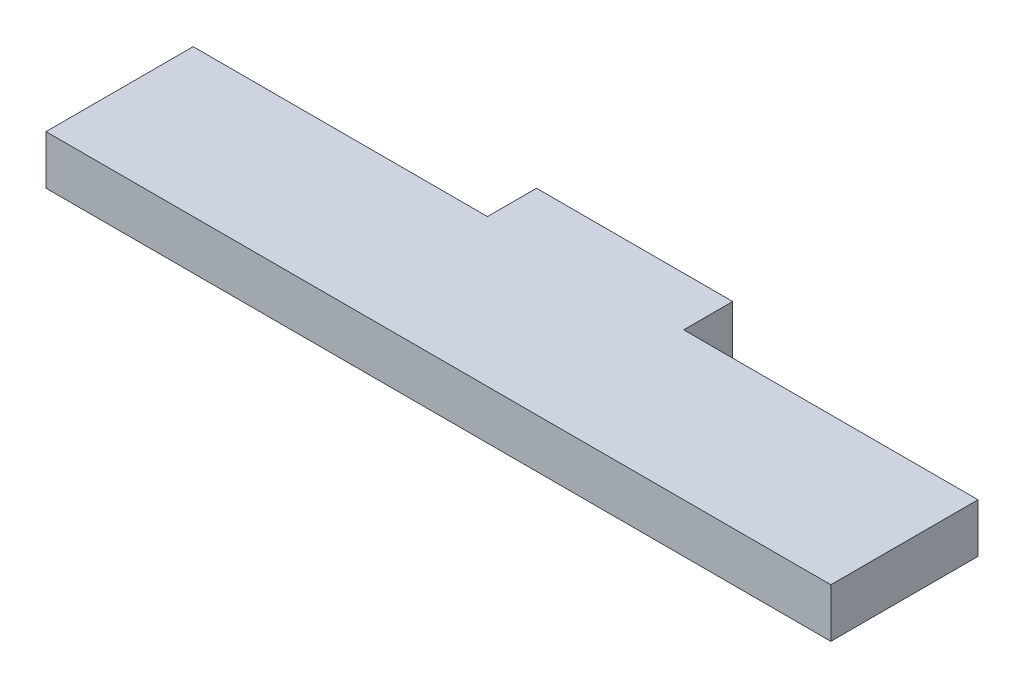
from build123d import *

# Parameters (mm, degrees)
SKETCH1_W               = 101.6
SKETCH1_H               = 25.4
BOSS_EXTRUDE1_DEPTH     = 6.35
SKETCH2_W               = 38.1
SKETCH2_H               = 6.35
CUT_EXTRUDE1_DEPTH      = 1
CUT_EXTRUDE1_DEPTH_BACK = 7.35


with BuildPart() as part:
    # Sketch1 → Boss-Extrude1 (new body)
    with BuildSketch(Plane(origin=(0, 0, 0), x_dir=(1, 0, 0), z_dir=(0, 1, 0))):
        with Locations((29.657499604, 6.35)):
            Rectangle(SKETCH1_W, SKETCH1_H)
    extrude(amount=BOSS_EXTRUDE1_DEPTH)

    # Sketch2 → Cut-Extrude1 (cut, two sides)
    with BuildSketch(Plane(origin=(0, 6.35, 0), x_dir=(1, 0, 0), z_dir=(0, 1, 0))) as cut_extrude1_sk:
        with Locations((-2.092500396, 15.875)):
            Rectangle(SKETCH2_W, SKETCH2_H)
        with Locations((61.407499604, 15.875)):
            Rectangle(SKETCH2_W, SKETCH2_H)
    extrude(amount=CUT_EXTRUDE1_DEPTH, mode=Mode.SUBTRACT)
    extrude(cut_extrude1_sk.sketch, amount=-CUT_EXTRUDE1_DEPTH_BACK, mode=Mode.SUBTRACT)


solid = part.part
